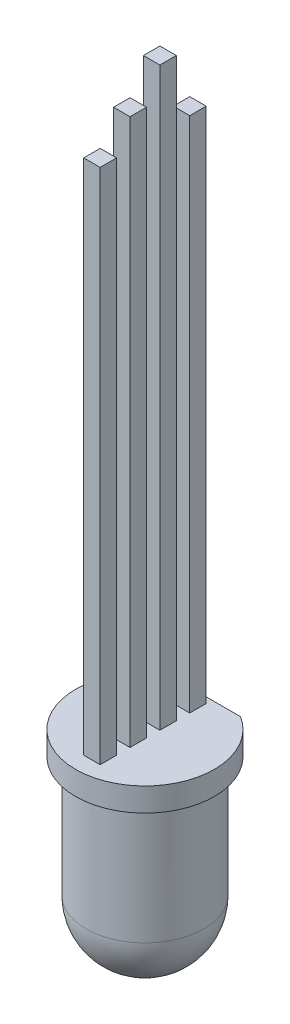
from build123d import *

# Parameters (mm, degrees)
ENL_V_MAT_EXTRU_1_REACH = 3
ESQUISSE3_W             = 0.7
ESQUISSE3_H             = 0.7
BOSS_EXTRU_1_DEPTH      = 24.5
ENL_V_START             = -3.3
ENL_V_MAT_EXTRU_2_DEPTH = 5.9


with BuildPart() as part:
    # Esquisse1 → Révolution1 (revolve)
    with BuildSketch(Plane.XY):
        with BuildLine():
            Line((2.5, 7.6), (2.5, 2.5))
            ThreePointArc((2.5, 2.5), (1.767766953, 0.732233047), (0, 0))
            Line((0, 0), (0, 8.6))
            Line((0, 8.6), (2.95, 8.6))
            Line((2.95, 8.6), (2.95, 7.6))
            Line((2.95, 7.6), (2.5, 7.6))
        make_face()
    revolve(axis=Axis((0, 0, 0), (0, 1, 0)))

    # Esquisse2 → Enlèv. mat.-Extru.1 (cut, up to next)
    with BuildSketch(Plane(origin=(0, 7.6, 0), x_dir=(-1, 0, 0), z_dir=(0, -1, 0)), mode=Mode.PRIVATE) as enl_v_mat_extru_1_sk1:
        Polygon((2.031643218, 2.5), (-2.119175806, 2.5), (-0.304277426, 5.41579693), align=None)
    enl_v_mat_extru_1_tool1 = extrude(enl_v_mat_extru_1_sk1.sketch, amount=-ENL_V_MAT_EXTRU_1_REACH, mode=Mode.PRIVATE) & part.part
    add(enl_v_mat_extru_1_tool1.solids().sort_by_distance((0.130603, 7.6, -3.471932))[0], mode=Mode.SUBTRACT)

    # Esquisse3 → Boss.-Extru.1 (add)
    with BuildSketch(Plane(origin=(0, 8.6, 0), x_dir=(1, 0, 0), z_dir=(0, 1, 0))):
        with Locations((0, 1.905)):
            Rectangle(ESQUISSE3_W, ESQUISSE3_H)
        with Locations((0, -0.635)):
            Rectangle(ESQUISSE3_W, ESQUISSE3_H)
        with Locations((0, -1.905)):
            Rectangle(ESQUISSE3_W, ESQUISSE3_H)
        with Locations((0, 0.635)):
            Rectangle(ESQUISSE3_W, ESQUISSE3_H)
    extrude(amount=BOSS_EXTRU_1_DEPTH)

    # Esquisse4 → Enlèv. mat.-Extru.2 (cut)
    with BuildSketch(Plane.ZY.offset(0.35).offset(ENL_V_START)):
        Polygon((-2.885095567, 30.6), (-1.265657514, 30.6), (-1.265657514, 33.921907916), (0, 33.921907916), (0, 31.83), (1.344412991, 31.83), (1.344412991, 30.6), (2.897512796, 30.6), (2.897512796, 34.676886987), (-2.885095567, 34.676886987), align=None)
    extrude(amount=ENL_V_MAT_EXTRU_2_DEPTH, mode=Mode.SUBTRACT)


solid = part.part
